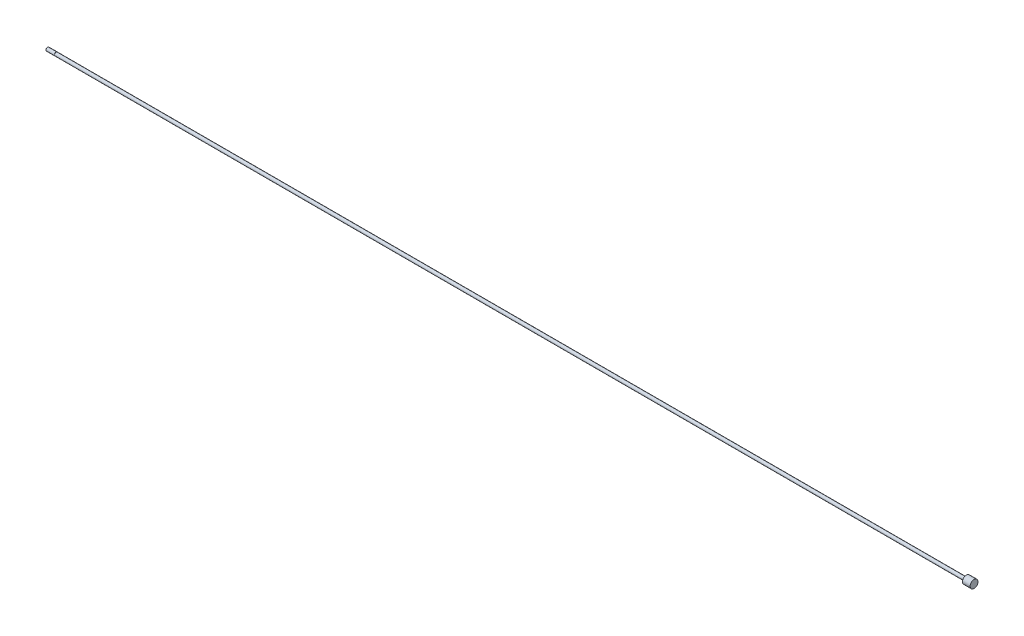
from build123d import *

# Parameters (mm, degrees)
SKETCH3_W = 0.254
SKETCH3_H = 0.508


with BuildPart() as part:
    # Sketch1 → Revolve1 (revolve)
    with BuildSketch(Plane.XY):
        Polygon((0, 0), (0, 2.3749), (1300.1752, 2.3749), (1300.1752, 5.61975), (1311.1988, 5.61975), (1311.1988, 0), align=None)
    revolve(axis=Axis((1311.1988, 0, 0), (-1, 0, 0)))

    # Sketch2 → Revolve2 (revolve)
    with BuildSketch(Plane.XY):
        Polygon((-12.7, 0), (-12.7, 1.94056), (-12.22756, 2.413), (0, 2.413), (0, 0), align=None)
    revolve(axis=Axis((0, 0, 0), (-1, 0, 0)))

    # Sketch3 → Cut-Revolve1 (revolve, cut)
    with BuildSketch(Plane.XY):
        with Locations((-0.127, 2.413)):
            Rectangle(SKETCH3_W, SKETCH3_H)
    revolve(axis=Axis((0, 0, 0), (-1, 0, 0)), mode=Mode.SUBTRACT)


solid = part.part
